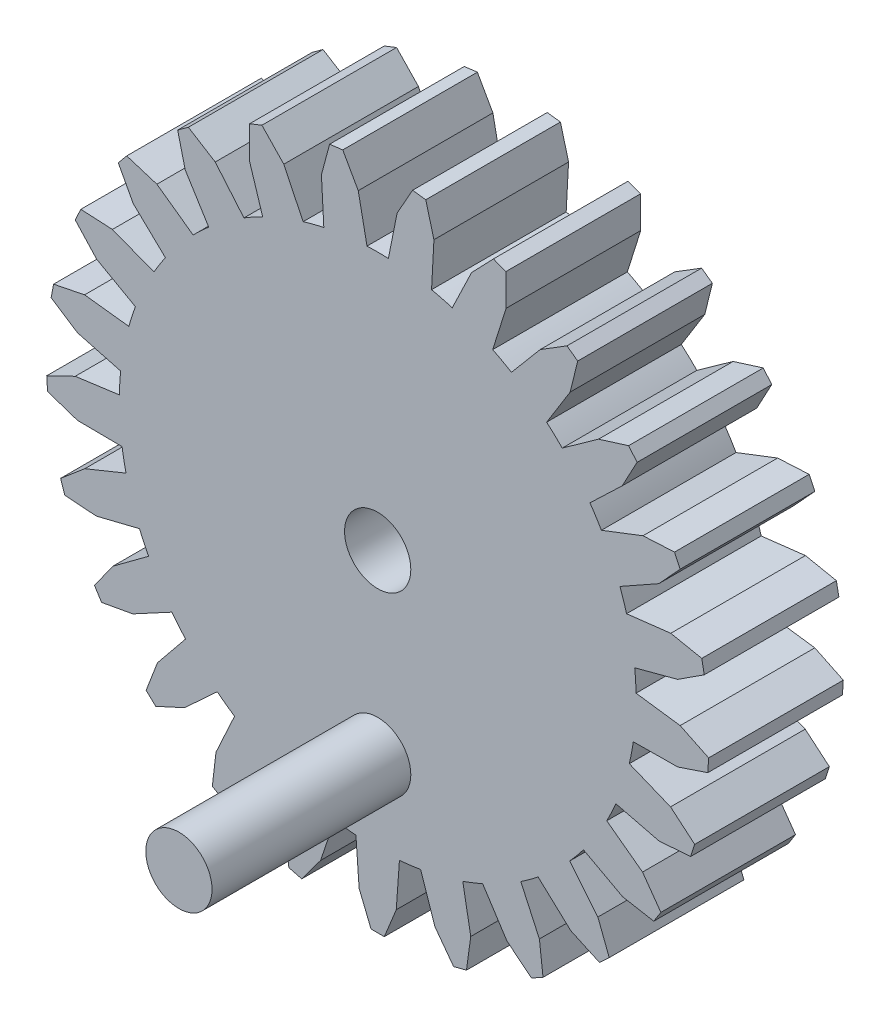
from build123d import *

# Parameters (mm, degrees)
BOSS_EXTRUDE1_DEPTH = 10.16
SKETCH2_R           = 2.5
CUT_EXTRUDE1_DEPTH  = 10.16
SKETCH5_R           = 2.5
BOSS_EXTRUDE2_DEPTH = 15


with BuildPart() as part:
    # Sketch1 → Boss-Extrude1 (new body)
    with BuildSketch(Plane.XY):
        with BuildLine():
            Line((21.369115072, -12.969065822), (19.986578913, -11.025302977))
            Line((19.986578913, -11.025302977), (17.28565357, -9.025307787))
            ThreePointArc((17.28565357, -9.025307787), (17.644127523, -8.302696186), (17.972409434, -7.565877287))
            Line((17.972409434, -7.565877287), (21.235066822, -8.372131118))
            Line((21.235066822, -8.372131118), (23.614023549, -8.19839247))
            Line((23.614023549, -8.19839247), (23.923040543, -7.247335954))
            Line((23.923040543, -7.247335954), (22.100545137, -5.708462756))
            Line((22.100545137, -5.708462756), (18.987095752, -4.442993911))
            ThreePointArc((18.987095752, -4.442993911), (19.154601389, -3.653935634), (19.289330312, -2.858624865))
            Line((19.289330312, -2.858624865), (22.649992492, -2.828158852))
            Line((22.649992492, -2.828158852), (24.911002874, -2.068256043))
            Line((24.911002874, -2.068256043), (24.973793394, -1.070229315))
            Line((24.973793394, -1.070229315), (22.82585283, -0.032938825))
            Line((22.82585283, -0.032938825), (19.495508879, 0.418489613))
            ThreePointArc((19.495508879, 0.418489613), (19.461521204, 1.224415131), (19.394231625, 2.02824547))
            Line((19.394231625, 2.02824547), (22.641735833, 2.893517036))
            Line((22.641735833, 2.893517036), (24.642732273, 4.191836518))
            Line((24.642732273, 4.191836518), (24.455350958, 5.174123768))
            Line((24.455350958, 5.174123768), (22.116928242, 5.644654774))
            Line((22.116928242, 5.644654774), (18.778947483, 5.253677896))
            ThreePointArc((18.778947483, 5.253677896), (18.545602068, 6.02583139), (18.280522038, 6.787673684))
            Line((18.280522038, 6.787673684), (21.210815641, 8.433382607))
            Line((21.210815641, 8.433382607), (22.826068173, 10.188540573))
            Line((22.826068173, 10.188540573), (22.400288882, 11.093367626))
            Line((22.400288882, 11.093367626), (20.018315712, 10.967573953))
            Line((20.018315712, 10.967573953), (16.882435753, 9.758758274))
            ThreePointArc((16.882435753, 9.758758274), (16.464394547, 10.448622502), (16.01818002, 11.120607396))
            Line((16.01818002, 11.120607396), (18.447141895, 13.443347733))
            Line((18.447141895, 13.443347733), (19.575158262, 15.545061154))
            Line((19.575158262, 15.545061154), (18.937734272, 16.315574397))
            Line((18.937734272, 16.315574397), (16.661878784, 15.601360125))
            Line((16.661878784, 15.601360125), (13.925138495, 13.65065998))
            ThreePointArc((13.925138495, 13.65065998), (13.348668566, 14.214888235), (12.749356841, 14.754792447))
            Line((12.749356841, 14.754792447), (14.524366379, 17.60861788))
            Line((14.524366379, 17.60861788), (15.094269164, 19.924828372))
            Line((15.094269164, 19.924828372), (14.28525217, 20.512613624))
            Line((14.28525217, 20.512613624), (12.258514734, 19.254855463))
            Line((12.258514734, 19.254855463), (10.092873572, 16.684840516))
            ThreePointArc((10.092873572, 16.684840516), (9.394196645, 17.087980261), (8.679444682, 17.461879624))
            Line((8.679444682, 17.461879624), (9.688971507, 20.667473805))
            Line((9.688971507, 20.667473805), (9.664951622, 23.052645345))
            Line((9.664951622, 23.052645345), (8.735175137, 23.420769898))
            Line((8.735175137, 23.420769898), (7.084903119, 21.698497417))
            Line((7.084903119, 21.698497417), (5.626436284, 18.67065116))
            ThreePointArc((5.626436284, 18.67065116), (4.8494528, 18.887371642), (4.064171094, 19.071772684))
            Line((4.064171094, 19.071772684), (4.244782922, 22.427716342))
            Line((4.244782922, 22.427716342), (3.628349625, 24.731979829))
            Line((3.628349625, 24.731979829), (2.636234924, 24.857313063))
            Line((2.636234924, 24.857313063), (1.466120985, 22.778742977))
            Line((1.466120985, 22.778742977), (0.806469312, 19.483316126))
            ThreePointArc((0.806469312, 19.483316126), (0, 19.5), (-0.806469312, 19.483316126))
            Line((-0.806469312, 19.483316126), (-1.466120985, 22.778742977))
            Line((-1.466120985, 22.778742977), (-2.636234924, 24.857313063))
            Line((-2.636234924, 24.857313063), (-3.628349625, 24.731979829))
            Line((-3.628349625, 24.731979829), (-4.244782922, 22.427716342))
            Line((-4.244782922, 22.427716342), (-4.064171094, 19.071772684))
            ThreePointArc((-4.064171094, 19.071772684), (-4.8494528, 18.887371642), (-5.626436284, 18.67065116))
            Line((-5.626436284, 18.67065116), (-7.084903119, 21.698497417))
            Line((-7.084903119, 21.698497417), (-8.735175137, 23.420769898))
            Line((-8.735175137, 23.420769898), (-9.664951622, 23.052645345))
            Line((-9.664951622, 23.052645345), (-9.688971507, 20.667473805))
            Line((-9.688971507, 20.667473805), (-8.679444682, 17.461879624))
            ThreePointArc((-8.679444682, 17.461879624), (-9.394196645, 17.087980261), (-10.092873572, 16.684840516))
            Line((-10.092873572, 16.684840516), (-12.258514734, 19.254855463))
            Line((-12.258514734, 19.254855463), (-14.28525217, 20.512613624))
            Line((-14.28525217, 20.512613624), (-15.094269164, 19.924828372))
            Line((-15.094269164, 19.924828372), (-14.524366379, 17.60861788))
            Line((-14.524366379, 17.60861788), (-12.749356841, 14.754792447))
            ThreePointArc((-12.749356841, 14.754792447), (-13.348668566, 14.214888235), (-13.925138495, 13.65065998))
            Line((-13.925138495, 13.65065998), (-16.661878784, 15.601360125))
            Line((-16.661878784, 15.601360125), (-18.937734272, 16.315574397))
            Line((-18.937734272, 16.315574397), (-19.575158262, 15.545061154))
            Line((-19.575158262, 15.545061154), (-18.447141895, 13.443347733))
            Line((-18.447141895, 13.443347733), (-16.01818002, 11.120607396))
            ThreePointArc((-16.01818002, 11.120607396), (-16.464394547, 10.448622502), (-16.882435753, 9.758758274))
            Line((-16.882435753, 9.758758274), (-20.018315712, 10.967573953))
            Line((-20.018315712, 10.967573953), (-22.400288882, 11.093367626))
            Line((-22.400288882, 11.093367626), (-22.826068173, 10.188540573))
            Line((-22.826068173, 10.188540573), (-21.210815641, 8.433382607))
            Line((-21.210815641, 8.433382607), (-18.280522038, 6.787673684))
            ThreePointArc((-18.280522038, 6.787673684), (-18.545602068, 6.02583139), (-18.778947483, 5.253677896))
            Line((-18.778947483, 5.253677896), (-22.116928242, 5.644654774))
            Line((-22.116928242, 5.644654774), (-24.455350958, 5.174123768))
            Line((-24.455350958, 5.174123768), (-24.642732273, 4.191836518))
            Line((-24.642732273, 4.191836518), (-22.641735833, 2.893517036))
            Line((-22.641735833, 2.893517036), (-19.394231625, 2.02824547))
            ThreePointArc((-19.394231625, 2.02824547), (-19.461521204, 1.224415131), (-19.495508879, 0.418489613))
            Line((-19.495508879, 0.418489613), (-22.82585283, -0.032938825))
            Line((-22.82585283, -0.032938825), (-24.973793394, -1.070229315))
            Line((-24.973793394, -1.070229315), (-24.911002874, -2.068256043))
            Line((-24.911002874, -2.068256043), (-22.649992492, -2.828158852))
            Line((-22.649992492, -2.828158852), (-19.289330312, -2.858624865))
            ThreePointArc((-19.289330312, -2.858624865), (-19.154601389, -3.653935634), (-18.987095752, -4.442993911))
            Line((-18.987095752, -4.442993911), (-22.100545137, -5.708462756))
            Line((-22.100545137, -5.708462756), (-23.923040543, -7.247335954))
            Line((-23.923040543, -7.247335954), (-23.614023549, -8.19839247))
            Line((-23.614023549, -8.19839247), (-21.235066822, -8.372131118))
            Line((-21.235066822, -8.372131118), (-17.972409434, -7.565877287))
            ThreePointArc((-17.972409434, -7.565877287), (-17.644127523, -8.302696186), (-17.28565357, -9.025307787))
            Line((-17.28565357, -9.025307787), (-19.986578913, -11.025302977))
            Line((-19.986578913, -11.025302977), (-21.369115072, -12.969065822))
            Line((-21.369115072, -12.969065822), (-20.833288277, -13.813393747))
            Line((-20.833288277, -13.813393747), (-18.485863806, -13.390051595))
            Line((-18.485863806, -13.390051595), (-15.526215974, -11.797737814))
            ThreePointArc((-15.526215974, -11.797737814), (-15.025008234, -12.4297678), (-14.498090202, -13.040528383))
            Line((-14.498090202, -13.040528383), (-16.61678243, -15.649382865))
            Line((-16.61678243, -15.649382865), (-17.472489512, -17.875901587))
            Line((-17.472489512, -17.875901587), (-16.743520884, -18.560448692))
            Line((-16.743520884, -18.560448692), (-14.575125981, -17.566625886))
            Line((-14.575125981, -17.566625886), (-12.104453263, -15.288303085))
            ThreePointArc((-12.104453263, -15.288303085), (-11.46181242, -15.77583139), (-10.799558506, -16.23636462))
            Line((-10.799558506, -16.23636462), (-12.202892395, -19.290154472))
            Line((-12.202892395, -19.290154472), (-12.478003175, -21.659528712))
            Line((-12.478003175, -21.659528712), (-11.601696495, -22.141282386))
            Line((-11.601696495, -22.141282386), (-9.748579387, -20.639424467))
            Line((-9.748579387, -20.639424467), (-7.922123236, -17.818248046))
            ThreePointArc((-7.922123236, -17.818248046), (-7.178428777, -18.130641475), (-6.422450831, -18.412010355))
            Line((-6.422450831, -18.412010355), (-7.022249752, -21.71885473))
            Line((-7.022249752, -21.71885473), (-6.699478009, -24.08220799))
            Line((-6.699478009, -24.08220799), (-5.730894848, -24.330897877))
            Line((-5.730894848, -24.330897877), (-4.309493697, -22.415372101))
            Line((-4.309493697, -22.415372101), (-3.242017071, -19.228606952))
            ThreePointArc((-3.242017071, -19.228606952), (-2.443998055, -19.346236676), (-1.64179695, -19.430761765))
            Line((-1.64179695, -19.430761765), (-1.40037333, -22.782879469))
            Line((-1.40037333, -22.782879469), (-0.5, -24.991713572))
            Line((-0.5, -24.991713572), (0.5, -24.991713572))
            Line((0.5, -24.991713572), (1.40037333, -22.782879469))
            Line((1.40037333, -22.782879469), (1.64179695, -19.430761765))
            ThreePointArc((1.64179695, -19.430761765), (2.443998055, -19.346236676), (3.242017071, -19.228606952))
            Line((3.242017071, -19.228606952), (4.309493697, -22.415372101))
            Line((4.309493697, -22.415372101), (5.730894848, -24.330897877))
            Line((5.730894848, -24.330897877), (6.699478009, -24.08220799))
            Line((6.699478009, -24.08220799), (7.022249752, -21.71885473))
            Line((7.022249752, -21.71885473), (6.422450831, -18.412010355))
            ThreePointArc((6.422450831, -18.412010355), (7.178428777, -18.130641475), (7.922123236, -17.818248046))
            Line((7.922123236, -17.818248046), (9.748579387, -20.639424467))
            Line((9.748579387, -20.639424467), (11.601696495, -22.141282386))
            Line((11.601696495, -22.141282386), (12.478003175, -21.659528712))
            Line((12.478003175, -21.659528712), (12.202892395, -19.290154472))
            Line((12.202892395, -19.290154472), (10.799558506, -16.23636462))
            ThreePointArc((10.799558506, -16.23636462), (11.46181242, -15.77583139), (12.104453263, -15.288303085))
            Line((12.104453263, -15.288303085), (14.575125981, -17.566625886))
            Line((14.575125981, -17.566625886), (16.743520884, -18.560448692))
            Line((16.743520884, -18.560448692), (17.472489512, -17.875901587))
            Line((17.472489512, -17.875901587), (16.61678243, -15.649382865))
            Line((16.61678243, -15.649382865), (14.498090202, -13.040528383))
            ThreePointArc((14.498090202, -13.040528383), (15.025008234, -12.4297678), (15.526215974, -11.797737814))
            Line((15.526215974, -11.797737814), (18.485863806, -13.390051595))
            Line((18.485863806, -13.390051595), (20.833288277, -13.813393747))
            Line((20.833288277, -13.813393747), (21.369115072, -12.969065822))
        make_face()
    extrude(amount=BOSS_EXTRUDE1_DEPTH)

    # Sketch2 → Cut-Extrude1 (cut)
    with BuildSketch(Plane.XY.offset(10.16)):
        Circle(SKETCH2_R)
    extrude(amount=-CUT_EXTRUDE1_DEPTH, mode=Mode.SUBTRACT)

    # Sketch5 → Boss-Extrude2 (add)
    with BuildSketch(Plane.XY.offset(10.16)):
        with Locations((0, -13.406225592)):
            Circle(SKETCH5_R)
    extrude(amount=BOSS_EXTRUDE2_DEPTH)


solid = part.part
